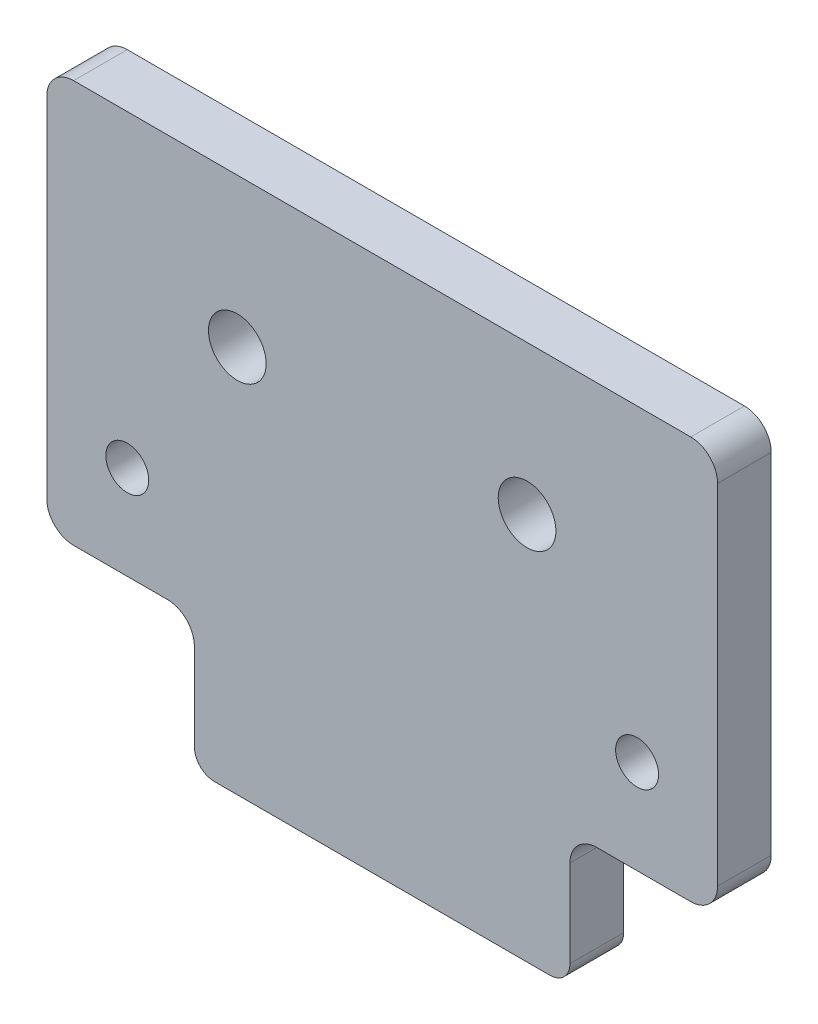
from build123d import *

# Parameters (mm, degrees)
SKETCH_1_W          = 50
SKETCH_1_H          = 30
EXTRUDE_1_DEPTH     = 4
SKETCH_3_R          = 2.15
CUT_EXTRUDE_2_DEPTH = 4
SKETCH_4_R          = 1.6
CUT_EXTRUDE_3_DEPTH = 5
SKETCH_5_W          = 28
SKETCH_5_H          = 10
EXTRUDE_2_DEPTH     = 4
FILLET_1_R          = 1.5
FILLET_2_R          = 2


with BuildPart() as part:
    # 草图1 → 凸台-拉伸1 (new body)
    with BuildSketch(Plane.XY):
        with Locations((25, 15)):
            Rectangle(SKETCH_1_W, SKETCH_1_H)
    extrude(amount=EXTRUDE_1_DEPTH)

    # 草图3 → 切除-拉伸2 (cut)
    with BuildSketch(Plane.XY.offset(4)):
        with Locations((14.2, 18.9)):
            Circle(SKETCH_3_R)
        with Locations((35.8, 18.9)):
            Circle(SKETCH_3_R)
    extrude(amount=-CUT_EXTRUDE_2_DEPTH, mode=Mode.SUBTRACT)

    # 草图4 → 切除-拉伸3 (cut, through all)
    with BuildSketch(Plane.XY.offset(4)):
        with Locations((44, 7)):
            Circle(SKETCH_4_R)
        with Locations((6, 7)):
            Circle(SKETCH_4_R)
    extrude(amount=-CUT_EXTRUDE_3_DEPTH, mode=Mode.SUBTRACT)

    # 草图5 → 凸台-拉伸2 (add)
    with BuildSketch(Plane.XY.offset(4)):
        with Locations((25, -5)):
            Rectangle(SKETCH_5_W, SKETCH_5_H)
    extrude(amount=-EXTRUDE_2_DEPTH)

    # 圆角1
    fillet_1_edges = [part.edges().sort_by_distance(p)[0] for p in [
        (11, -10, 2),
        (39, -10, 2),
    ]]
    fillet(fillet_1_edges, radius=FILLET_1_R)

    # 圆角2
    fillet_2_edges = [part.edges().sort_by_distance(p)[0] for p in [
        (11, 0, 2),
        (39, 0, 2),
        (0, 30, 2),
        (50, 30, 2),
        (50, 0, 2),
        (0, 0, 2),
    ]]
    fillet(fillet_2_edges, radius=FILLET_2_R)


solid = part.part
